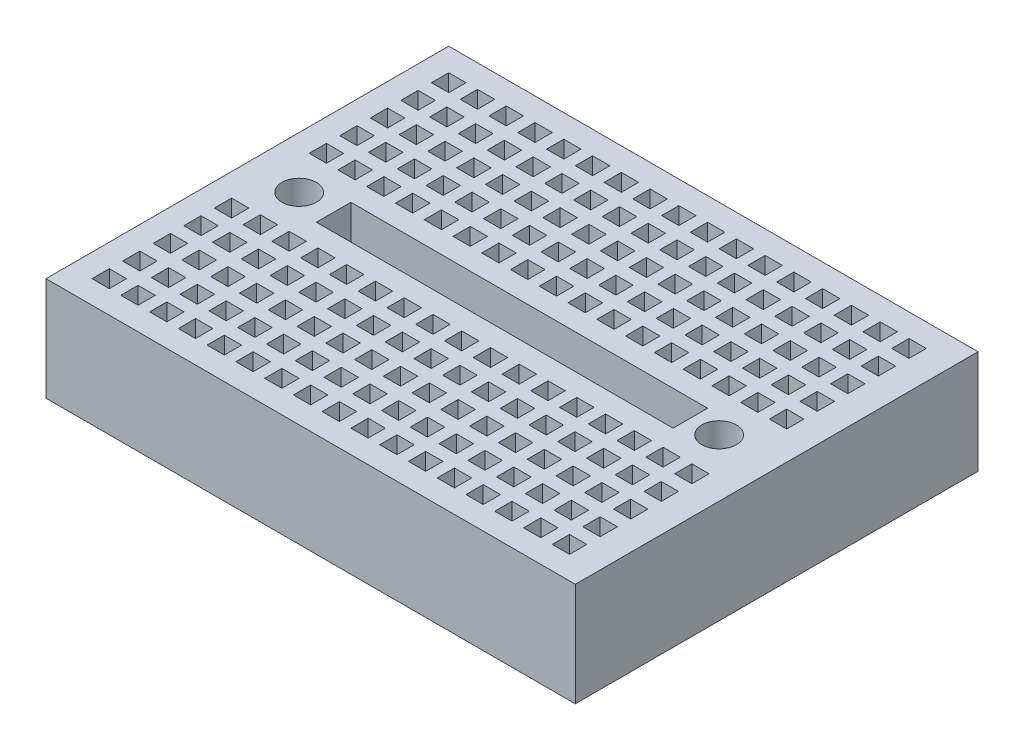
from build123d import *

# Parameters (mm, degrees)
SKETCH1_W           = 46
SKETCH1_H           = 35
BOSS_EXTRUDE1_DEPTH = 9
SKETCH2_R           = 1.5
SKETCH2_W           = 1.5
SKETCH2_H           = 1.5
SKETCH2_W_2         = 31
SKETCH2_H_2         = 3
CUT_EXTRUDE4_DEPTH  = 3


with BuildPart() as part:
    # Sketch1 → Boss-Extrude1 (new body)
    with BuildSketch(Plane(origin=(0, 0, 0), x_dir=(1, 0, 0), z_dir=(0, 1, 0))):
        Rectangle(SKETCH1_W, SKETCH1_H)
    extrude(amount=BOSS_EXTRUDE1_DEPTH)

    # Sketch2 → Cut-Extrude4 (cut)
    with BuildSketch(Plane(origin=(0, 9, 0), x_dir=(1, 0, 0), z_dir=(0, 1, 0))):
        with Locations((18, 0)):
            Circle(SKETCH2_R)
        with Locations((-18.5, 0)):
            Circle(SKETCH2_R)
        with Locations((-20.25, 14.75)):
            Rectangle(SKETCH2_W, SKETCH2_H)
        Rectangle(SKETCH2_W_2, SKETCH2_H_2)
        with Locations((-17.75, 14.75)):
            Rectangle(SKETCH2_W, SKETCH2_H)
        with Locations((-15.25, 14.75)):
            Rectangle(SKETCH2_W, SKETCH2_H)
        with Locations((-12.75, 14.75)):
            Rectangle(SKETCH2_W, SKETCH2_H)
        with Locations((-10.25, 14.75)):
            Rectangle(SKETCH2_W, SKETCH2_H)
        with Locations((-7.75, 14.75)):
            Rectangle(SKETCH2_W, SKETCH2_H)
        with Locations((-5.25, 14.75)):
            Rectangle(SKETCH2_W, SKETCH2_H)
        with Locations((-2.75, 14.75)):
            Rectangle(SKETCH2_W, SKETCH2_H)
        with Locations((-0.25, 14.75)):
            Rectangle(SKETCH2_W, SKETCH2_H)
        with Locations((2.25, 14.75)):
            Rectangle(SKETCH2_W, SKETCH2_H)
        with Locations((4.75, 14.75)):
            Rectangle(SKETCH2_W, SKETCH2_H)
        with Locations((7.25, 14.75)):
            Rectangle(SKETCH2_W, SKETCH2_H)
        with Locations((9.75, 14.75)):
            Rectangle(SKETCH2_W, SKETCH2_H)
        with Locations((12.25, 14.75)):
            Rectangle(SKETCH2_W, SKETCH2_H)
        with Locations((14.75, 14.75)):
            Rectangle(SKETCH2_W, SKETCH2_H)
        with Locations((17.25, 14.75)):
            Rectangle(SKETCH2_W, SKETCH2_H)
        with Locations((19.75, 14.75)):
            Rectangle(SKETCH2_W, SKETCH2_H)
        with Locations((-17.75, 12.092555369)):
            Rectangle(SKETCH2_W, SKETCH2_H)
        with Locations((-15.25, 12.092555369)):
            Rectangle(SKETCH2_W, SKETCH2_H)
        with Locations((-12.75, 12.092555369)):
            Rectangle(SKETCH2_W, SKETCH2_H)
        with Locations((-10.25, 12.092555369)):
            Rectangle(SKETCH2_W, SKETCH2_H)
        with Locations((-7.75, 12.092555369)):
            Rectangle(SKETCH2_W, SKETCH2_H)
        with Locations((-5.25, 12.092555369)):
            Rectangle(SKETCH2_W, SKETCH2_H)
        with Locations((-2.75, 12.092555369)):
            Rectangle(SKETCH2_W, SKETCH2_H)
        with Locations((-0.25, 12.092555369)):
            Rectangle(SKETCH2_W, SKETCH2_H)
        with Locations((2.25, 12.092555369)):
            Rectangle(SKETCH2_W, SKETCH2_H)
        with Locations((4.75, 12.092555369)):
            Rectangle(SKETCH2_W, SKETCH2_H)
        with Locations((7.25, 12.092555369)):
            Rectangle(SKETCH2_W, SKETCH2_H)
        with Locations((9.75, 12.092555369)):
            Rectangle(SKETCH2_W, SKETCH2_H)
        with Locations((12.25, 12.092555369)):
            Rectangle(SKETCH2_W, SKETCH2_H)
        with Locations((14.75, 12.092555369)):
            Rectangle(SKETCH2_W, SKETCH2_H)
        with Locations((17.25, 12.092555369)):
            Rectangle(SKETCH2_W, SKETCH2_H)
        with Locations((19.75, 12.092555369)):
            Rectangle(SKETCH2_W, SKETCH2_H)
        with Locations((-17.75, 9.435110738)):
            Rectangle(SKETCH2_W, SKETCH2_H)
        with Locations((-15.25, 9.435110738)):
            Rectangle(SKETCH2_W, SKETCH2_H)
        with Locations((-12.75, 9.435110738)):
            Rectangle(SKETCH2_W, SKETCH2_H)
        with Locations((-10.25, 9.435110738)):
            Rectangle(SKETCH2_W, SKETCH2_H)
        with Locations((-7.75, 9.435110738)):
            Rectangle(SKETCH2_W, SKETCH2_H)
        with Locations((-5.25, 9.435110738)):
            Rectangle(SKETCH2_W, SKETCH2_H)
        with Locations((-2.75, 9.435110738)):
            Rectangle(SKETCH2_W, SKETCH2_H)
        with Locations((-0.25, 9.435110738)):
            Rectangle(SKETCH2_W, SKETCH2_H)
        with Locations((2.25, 9.435110738)):
            Rectangle(SKETCH2_W, SKETCH2_H)
        with Locations((4.75, 9.435110738)):
            Rectangle(SKETCH2_W, SKETCH2_H)
        with Locations((7.25, 9.435110738)):
            Rectangle(SKETCH2_W, SKETCH2_H)
        with Locations((9.75, 9.435110738)):
            Rectangle(SKETCH2_W, SKETCH2_H)
        with Locations((12.25, 9.435110738)):
            Rectangle(SKETCH2_W, SKETCH2_H)
        with Locations((14.75, 9.435110738)):
            Rectangle(SKETCH2_W, SKETCH2_H)
        with Locations((17.25, 9.435110738)):
            Rectangle(SKETCH2_W, SKETCH2_H)
        with Locations((19.75, 9.435110738)):
            Rectangle(SKETCH2_W, SKETCH2_H)
        with Locations((-17.75, 6.777666107)):
            Rectangle(SKETCH2_W, SKETCH2_H)
        with Locations((-15.25, 6.777666107)):
            Rectangle(SKETCH2_W, SKETCH2_H)
        with Locations((-12.75, 6.777666107)):
            Rectangle(SKETCH2_W, SKETCH2_H)
        with Locations((-10.25, 6.777666107)):
            Rectangle(SKETCH2_W, SKETCH2_H)
        with Locations((-7.75, 6.777666107)):
            Rectangle(SKETCH2_W, SKETCH2_H)
        with Locations((-5.25, 6.777666107)):
            Rectangle(SKETCH2_W, SKETCH2_H)
        with Locations((-2.75, 6.777666107)):
            Rectangle(SKETCH2_W, SKETCH2_H)
        with Locations((-0.25, 6.777666107)):
            Rectangle(SKETCH2_W, SKETCH2_H)
        with Locations((2.25, 6.777666107)):
            Rectangle(SKETCH2_W, SKETCH2_H)
        with Locations((4.75, 6.777666107)):
            Rectangle(SKETCH2_W, SKETCH2_H)
        with Locations((7.25, 6.777666107)):
            Rectangle(SKETCH2_W, SKETCH2_H)
        with Locations((9.75, 6.777666107)):
            Rectangle(SKETCH2_W, SKETCH2_H)
        with Locations((12.25, 6.777666107)):
            Rectangle(SKETCH2_W, SKETCH2_H)
        with Locations((14.75, 6.777666107)):
            Rectangle(SKETCH2_W, SKETCH2_H)
        with Locations((17.25, 6.777666107)):
            Rectangle(SKETCH2_W, SKETCH2_H)
        with Locations((19.75, 6.777666107)):
            Rectangle(SKETCH2_W, SKETCH2_H)
        with Locations((-17.75, 4.120221476)):
            Rectangle(SKETCH2_W, SKETCH2_H)
        with Locations((-15.25, 4.120221476)):
            Rectangle(SKETCH2_W, SKETCH2_H)
        with Locations((-12.75, 4.120221476)):
            Rectangle(SKETCH2_W, SKETCH2_H)
        with Locations((-10.25, 4.120221476)):
            Rectangle(SKETCH2_W, SKETCH2_H)
        with Locations((-7.75, 4.120221476)):
            Rectangle(SKETCH2_W, SKETCH2_H)
        with Locations((-5.25, 4.120221476)):
            Rectangle(SKETCH2_W, SKETCH2_H)
        with Locations((-2.75, 4.120221476)):
            Rectangle(SKETCH2_W, SKETCH2_H)
        with Locations((-0.25, 4.120221476)):
            Rectangle(SKETCH2_W, SKETCH2_H)
        with Locations((2.25, 4.120221476)):
            Rectangle(SKETCH2_W, SKETCH2_H)
        with Locations((4.75, 4.120221476)):
            Rectangle(SKETCH2_W, SKETCH2_H)
        with Locations((7.25, 4.120221476)):
            Rectangle(SKETCH2_W, SKETCH2_H)
        with Locations((9.75, 4.120221476)):
            Rectangle(SKETCH2_W, SKETCH2_H)
        with Locations((12.25, 4.120221476)):
            Rectangle(SKETCH2_W, SKETCH2_H)
        with Locations((14.75, 4.120221476)):
            Rectangle(SKETCH2_W, SKETCH2_H)
        with Locations((17.25, 4.120221476)):
            Rectangle(SKETCH2_W, SKETCH2_H)
        with Locations((19.75, 4.120221476)):
            Rectangle(SKETCH2_W, SKETCH2_H)
        with Locations((-20.25, 12.092555369)):
            Rectangle(SKETCH2_W, SKETCH2_H)
        with Locations((-20.25, 9.435110738)):
            Rectangle(SKETCH2_W, SKETCH2_H)
        with Locations((-20.25, 6.777666107)):
            Rectangle(SKETCH2_W, SKETCH2_H)
        with Locations((-20.25, 4.120221476)):
            Rectangle(SKETCH2_W, SKETCH2_H)
        with Locations((-20.25, -4.120221476)):
            Rectangle(SKETCH2_W, SKETCH2_H)
        with Locations((-20.25, -6.777666107)):
            Rectangle(SKETCH2_W, SKETCH2_H)
        with Locations((-20.25, -9.435110738)):
            Rectangle(SKETCH2_W, SKETCH2_H)
        with Locations((-20.25, -12.092555369)):
            Rectangle(SKETCH2_W, SKETCH2_H)
        with Locations((19.75, -4.120221476)):
            Rectangle(SKETCH2_W, SKETCH2_H)
        with Locations((17.25, -4.120221476)):
            Rectangle(SKETCH2_W, SKETCH2_H)
        with Locations((14.75, -4.120221476)):
            Rectangle(SKETCH2_W, SKETCH2_H)
        with Locations((12.25, -4.120221476)):
            Rectangle(SKETCH2_W, SKETCH2_H)
        with Locations((9.75, -4.120221476)):
            Rectangle(SKETCH2_W, SKETCH2_H)
        with Locations((7.25, -4.120221476)):
            Rectangle(SKETCH2_W, SKETCH2_H)
        with Locations((4.75, -4.120221476)):
            Rectangle(SKETCH2_W, SKETCH2_H)
        with Locations((2.25, -4.120221476)):
            Rectangle(SKETCH2_W, SKETCH2_H)
        with Locations((-0.25, -4.120221476)):
            Rectangle(SKETCH2_W, SKETCH2_H)
        with Locations((-2.75, -4.120221476)):
            Rectangle(SKETCH2_W, SKETCH2_H)
        with Locations((-5.25, -4.120221476)):
            Rectangle(SKETCH2_W, SKETCH2_H)
        with Locations((-7.75, -4.120221476)):
            Rectangle(SKETCH2_W, SKETCH2_H)
        with Locations((-10.25, -4.120221476)):
            Rectangle(SKETCH2_W, SKETCH2_H)
        with Locations((-12.75, -4.120221476)):
            Rectangle(SKETCH2_W, SKETCH2_H)
        with Locations((-15.25, -4.120221476)):
            Rectangle(SKETCH2_W, SKETCH2_H)
        with Locations((-17.75, -4.120221476)):
            Rectangle(SKETCH2_W, SKETCH2_H)
        with Locations((19.75, -6.777666107)):
            Rectangle(SKETCH2_W, SKETCH2_H)
        with Locations((17.25, -6.777666107)):
            Rectangle(SKETCH2_W, SKETCH2_H)
        with Locations((14.75, -6.777666107)):
            Rectangle(SKETCH2_W, SKETCH2_H)
        with Locations((12.25, -6.777666107)):
            Rectangle(SKETCH2_W, SKETCH2_H)
        with Locations((9.75, -6.777666107)):
            Rectangle(SKETCH2_W, SKETCH2_H)
        with Locations((7.25, -6.777666107)):
            Rectangle(SKETCH2_W, SKETCH2_H)
        with Locations((4.75, -6.777666107)):
            Rectangle(SKETCH2_W, SKETCH2_H)
        with Locations((2.25, -6.777666107)):
            Rectangle(SKETCH2_W, SKETCH2_H)
        with Locations((-0.25, -6.777666107)):
            Rectangle(SKETCH2_W, SKETCH2_H)
        with Locations((-2.75, -6.777666107)):
            Rectangle(SKETCH2_W, SKETCH2_H)
        with Locations((-5.25, -6.777666107)):
            Rectangle(SKETCH2_W, SKETCH2_H)
        with Locations((-7.75, -6.777666107)):
            Rectangle(SKETCH2_W, SKETCH2_H)
        with Locations((-10.25, -6.777666107)):
            Rectangle(SKETCH2_W, SKETCH2_H)
        with Locations((-12.75, -6.777666107)):
            Rectangle(SKETCH2_W, SKETCH2_H)
        with Locations((-15.25, -6.777666107)):
            Rectangle(SKETCH2_W, SKETCH2_H)
        with Locations((-17.75, -6.777666107)):
            Rectangle(SKETCH2_W, SKETCH2_H)
        with Locations((19.75, -9.435110738)):
            Rectangle(SKETCH2_W, SKETCH2_H)
        with Locations((17.25, -9.435110738)):
            Rectangle(SKETCH2_W, SKETCH2_H)
        with Locations((14.75, -9.435110738)):
            Rectangle(SKETCH2_W, SKETCH2_H)
        with Locations((12.25, -9.435110738)):
            Rectangle(SKETCH2_W, SKETCH2_H)
        with Locations((9.75, -9.435110738)):
            Rectangle(SKETCH2_W, SKETCH2_H)
        with Locations((7.25, -9.435110738)):
            Rectangle(SKETCH2_W, SKETCH2_H)
        with Locations((4.75, -9.435110738)):
            Rectangle(SKETCH2_W, SKETCH2_H)
        with Locations((2.25, -9.435110738)):
            Rectangle(SKETCH2_W, SKETCH2_H)
        with Locations((-0.25, -9.435110738)):
            Rectangle(SKETCH2_W, SKETCH2_H)
        with Locations((-2.75, -9.435110738)):
            Rectangle(SKETCH2_W, SKETCH2_H)
        with Locations((-5.25, -9.435110738)):
            Rectangle(SKETCH2_W, SKETCH2_H)
        with Locations((-7.75, -9.435110738)):
            Rectangle(SKETCH2_W, SKETCH2_H)
        with Locations((-10.25, -9.435110738)):
            Rectangle(SKETCH2_W, SKETCH2_H)
        with Locations((-12.75, -9.435110738)):
            Rectangle(SKETCH2_W, SKETCH2_H)
        with Locations((-15.25, -9.435110738)):
            Rectangle(SKETCH2_W, SKETCH2_H)
        with Locations((-17.75, -9.435110738)):
            Rectangle(SKETCH2_W, SKETCH2_H)
        with Locations((19.75, -12.092555369)):
            Rectangle(SKETCH2_W, SKETCH2_H)
        with Locations((17.25, -12.092555369)):
            Rectangle(SKETCH2_W, SKETCH2_H)
        with Locations((14.75, -12.092555369)):
            Rectangle(SKETCH2_W, SKETCH2_H)
        with Locations((12.25, -12.092555369)):
            Rectangle(SKETCH2_W, SKETCH2_H)
        with Locations((9.75, -12.092555369)):
            Rectangle(SKETCH2_W, SKETCH2_H)
        with Locations((7.25, -12.092555369)):
            Rectangle(SKETCH2_W, SKETCH2_H)
        with Locations((4.75, -12.092555369)):
            Rectangle(SKETCH2_W, SKETCH2_H)
        with Locations((2.25, -12.092555369)):
            Rectangle(SKETCH2_W, SKETCH2_H)
        with Locations((-0.25, -12.092555369)):
            Rectangle(SKETCH2_W, SKETCH2_H)
        with Locations((-2.75, -12.092555369)):
            Rectangle(SKETCH2_W, SKETCH2_H)
        with Locations((-5.25, -12.092555369)):
            Rectangle(SKETCH2_W, SKETCH2_H)
        with Locations((-7.75, -12.092555369)):
            Rectangle(SKETCH2_W, SKETCH2_H)
        with Locations((-10.25, -12.092555369)):
            Rectangle(SKETCH2_W, SKETCH2_H)
        with Locations((-12.75, -12.092555369)):
            Rectangle(SKETCH2_W, SKETCH2_H)
        with Locations((-15.25, -12.092555369)):
            Rectangle(SKETCH2_W, SKETCH2_H)
        with Locations((-17.75, -12.092555369)):
            Rectangle(SKETCH2_W, SKETCH2_H)
        with Locations((19.75, -14.75)):
            Rectangle(SKETCH2_W, SKETCH2_H)
        with Locations((17.25, -14.75)):
            Rectangle(SKETCH2_W, SKETCH2_H)
        with Locations((14.75, -14.75)):
            Rectangle(SKETCH2_W, SKETCH2_H)
        with Locations((12.25, -14.75)):
            Rectangle(SKETCH2_W, SKETCH2_H)
        with Locations((9.75, -14.75)):
            Rectangle(SKETCH2_W, SKETCH2_H)
        with Locations((7.25, -14.75)):
            Rectangle(SKETCH2_W, SKETCH2_H)
        with Locations((4.75, -14.75)):
            Rectangle(SKETCH2_W, SKETCH2_H)
        with Locations((2.25, -14.75)):
            Rectangle(SKETCH2_W, SKETCH2_H)
        with Locations((-0.25, -14.75)):
            Rectangle(SKETCH2_W, SKETCH2_H)
        with Locations((-2.75, -14.75)):
            Rectangle(SKETCH2_W, SKETCH2_H)
        with Locations((-5.25, -14.75)):
            Rectangle(SKETCH2_W, SKETCH2_H)
        with Locations((-7.75, -14.75)):
            Rectangle(SKETCH2_W, SKETCH2_H)
        with Locations((-10.25, -14.75)):
            Rectangle(SKETCH2_W, SKETCH2_H)
        with Locations((-12.75, -14.75)):
            Rectangle(SKETCH2_W, SKETCH2_H)
        with Locations((-15.25, -14.75)):
            Rectangle(SKETCH2_W, SKETCH2_H)
        with Locations((-17.75, -14.75)):
            Rectangle(SKETCH2_W, SKETCH2_H)
        with Locations((-20.25, -14.75)):
            Rectangle(SKETCH2_W, SKETCH2_H)
    extrude(amount=-CUT_EXTRUDE4_DEPTH, mode=Mode.SUBTRACT)


solid = part.part
